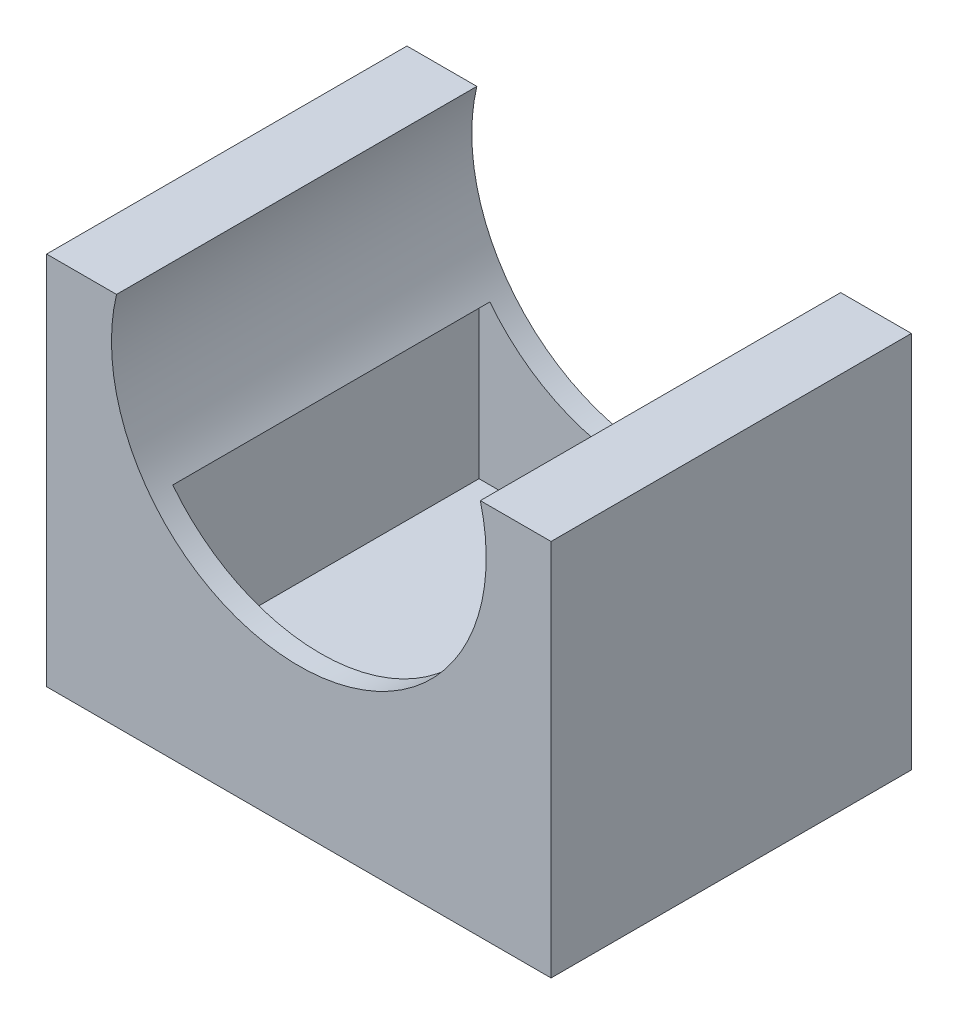
from build123d import *

# Parameters (mm, degrees)
SKETCH1_W           = 70
SKETCH1_H           = 10
BOSS_EXTRUDE2_DEPTH = 50
SKETCH2_W           = 44
SKETCH2_H           = 44
CUT_EXTRUDE6_DEPTH  = 10
SKETCH3_W           = 44
SKETCH3_H           = 44
CUT_EXTRUDE8_DEPTH  = 12
SKETCH6_W           = 70
SKETCH6_H           = 6
BOSS_EXTRUDE3_DEPTH = 50


with BuildPart() as part:
    # Sketch1 → Boss-Extrude2 (new body)
    with BuildSketch(Plane.XY):
        with BuildLine():
            Line((60.184895573, 46.459182221), (70, 46.459182221))
            Line((70, 46.459182221), (70, 10))
            Line((70, 10), (0, 10))
            Line((0, 10), (0, 46))
            Line((0, 46), (9.701778719, 46))
            ThreePointArc((9.701778719, 46), (35.236479929, 14.00107546), (60.184895573, 46.459182221))
        make_face()
        with Locations((35, 5)):
            Rectangle(SKETCH1_W, SKETCH1_H)
    extrude(amount=BOSS_EXTRUDE2_DEPTH)

    # Sketch2 → Cut-Extrude6 (cut)
    with BuildSketch(Plane(origin=(0, 14, 0), x_dir=(1, 0, 0), z_dir=(0, 1, 0))):
        with Locations((35, -25)):
            Rectangle(SKETCH2_W, SKETCH2_H)
    extrude(amount=CUT_EXTRUDE6_DEPTH, mode=Mode.SUBTRACT)

    # Sketch3 → Cut-Extrude8 (cut)
    with BuildSketch(Plane(origin=(0, 14, 0), x_dir=(1, 0, 0), z_dir=(0, 1, 0))):
        with Locations((35, -25)):
            Rectangle(SKETCH3_W, SKETCH3_H)
    extrude(amount=-CUT_EXTRUDE8_DEPTH, mode=Mode.SUBTRACT)

    # Sketch6 → Boss-Extrude3 (add)
    with BuildSketch(Plane.XY):
        with Locations((35, -3)):
            Rectangle(SKETCH6_W, SKETCH6_H)
    extrude(amount=BOSS_EXTRUDE3_DEPTH)


solid = part.part
